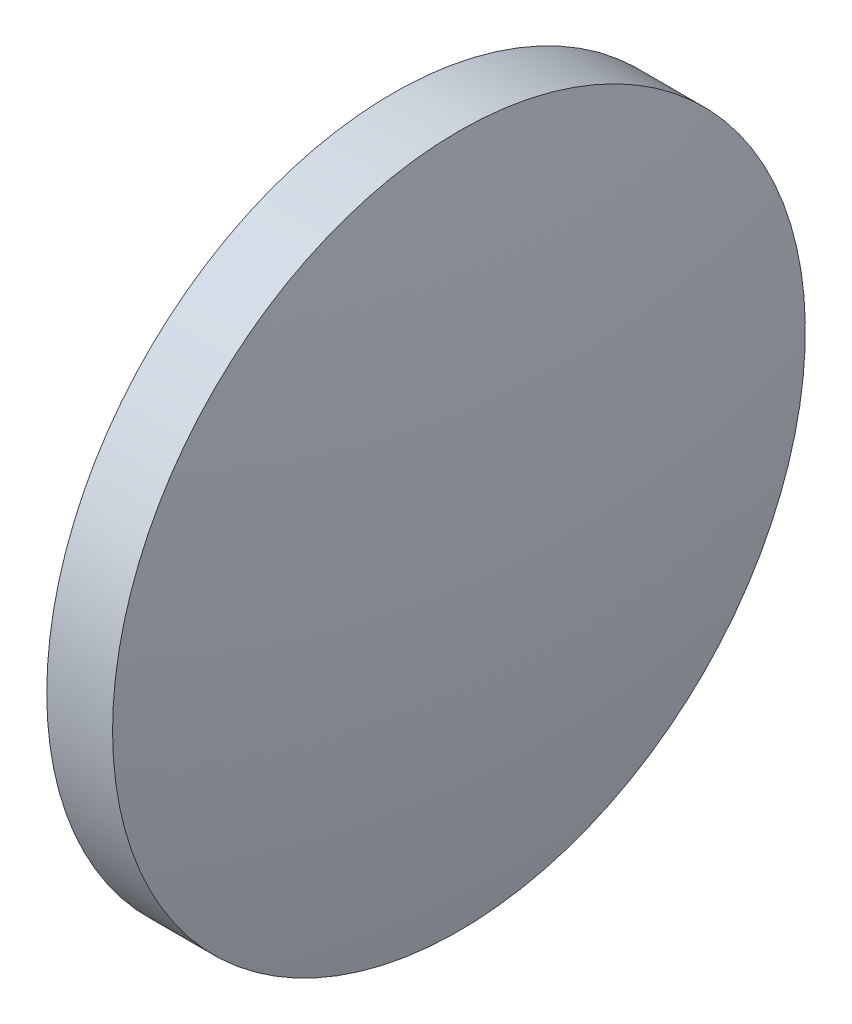
from build123d import *


with BuildPart() as part:
    # 草图1 → 旋转3 (revolve)
    with BuildSketch(Plane.XY):
        with BuildLine():
            Line((610.424373484, 147.602144211), (608.124373484, 147.602144211))
            Line((608.124373484, 147.602144211), (608.124373484, 155.602144211))
            Line((608.124373484, 155.602144211), (609.644373484, 155.602144211))
            ThreePointArc((609.644373484, 155.602144211), (610.228912244, 151.62111174), (610.424373484, 147.602144211))
        make_face()
    revolve(axis=Axis((606.201556779, 147.602144211, 0), (1, 0, 0)))


solid = part.part
